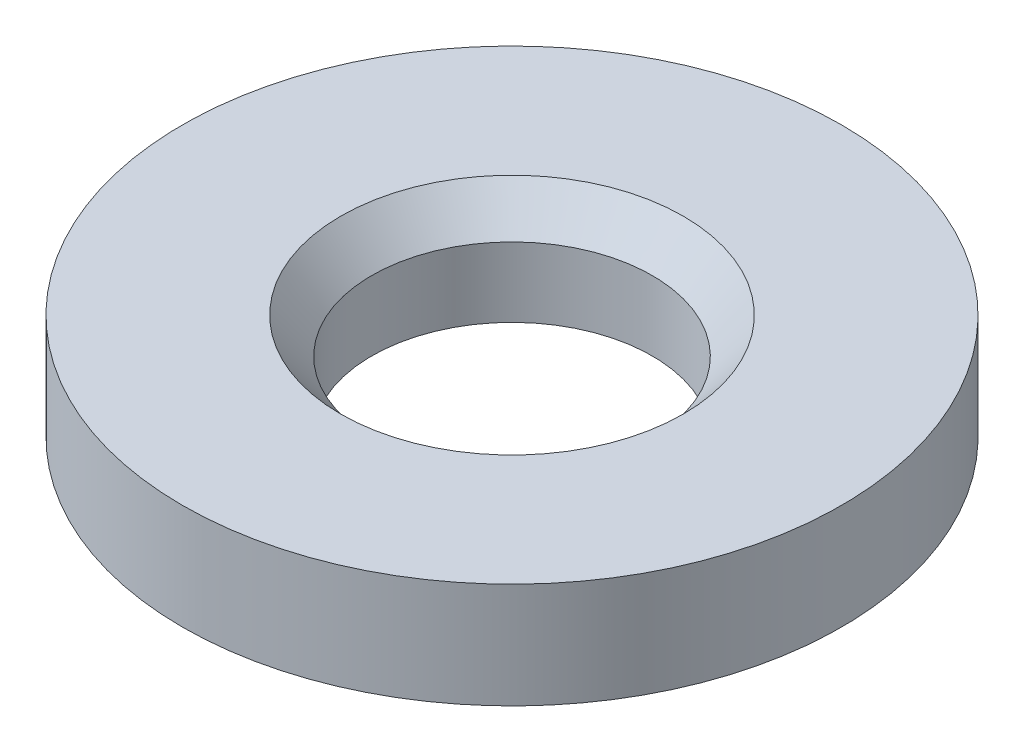
from build123d import *

# Parameters (mm, degrees)
SKETCH2_R           = 7.9375
BOSS_EXTRUDE1_DEPTH = 2.54


with BuildPart() as part:
    # Sketch2 → Boss-Extrude1 (new body)
    with BuildSketch(Plane(origin=(0, 0, 0), x_dir=(1, 0, 0), z_dir=(0, 1, 0))):
        Circle(SKETCH2_R)
    extrude(amount=BOSS_EXTRUDE1_DEPTH)

    # Sketch5 → CSK for #10 Flat Head Machine Screw (100)1 (revolve, cut)
    with BuildSketch(Plane(origin=(0, 2.54, 0), x_dir=(0, 0, 1), z_dir=(1, 0, 0))):
        Polygon((0, 0), (0, 2.54), (3.3782, 2.54), (3.3782, 0.861971048), (4.1275, 0), align=None)
    revolve(axis=Axis((0, 8.89, 0), (0, -1, 0)), mode=Mode.SUBTRACT)


solid = part.part
